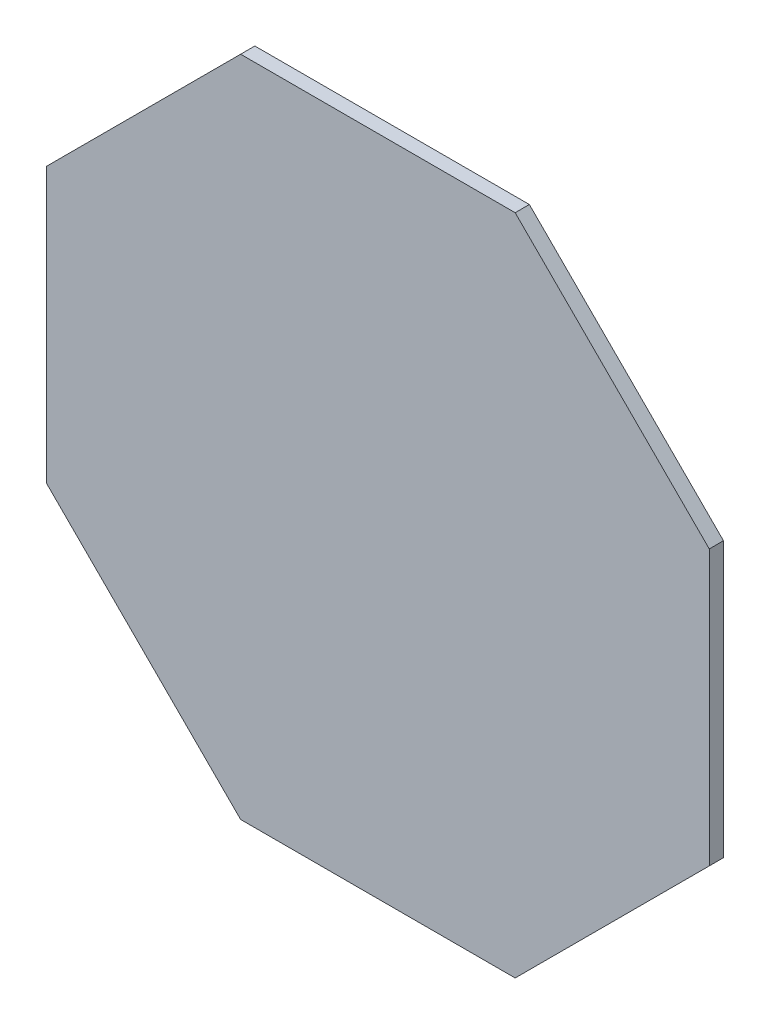
from build123d import *

# Parameters (mm, degrees)
BOSS_EXTRUDE2_DEPTH = 1.5


with BuildPart() as part:
    # Sketch2 → Boss-Extrude2 (new body)
    with BuildSketch(Plane.XY):
        Polygon((35, 14.497474683), (14.497474683, 35), (-14.497474683, 35), (-35, 14.497474683), (-35, -14.497474683), (-14.497474683, -35), (14.497474683, -35), (35, -14.497474683), align=None)
    extrude(amount=BOSS_EXTRUDE2_DEPTH)


solid = part.part
